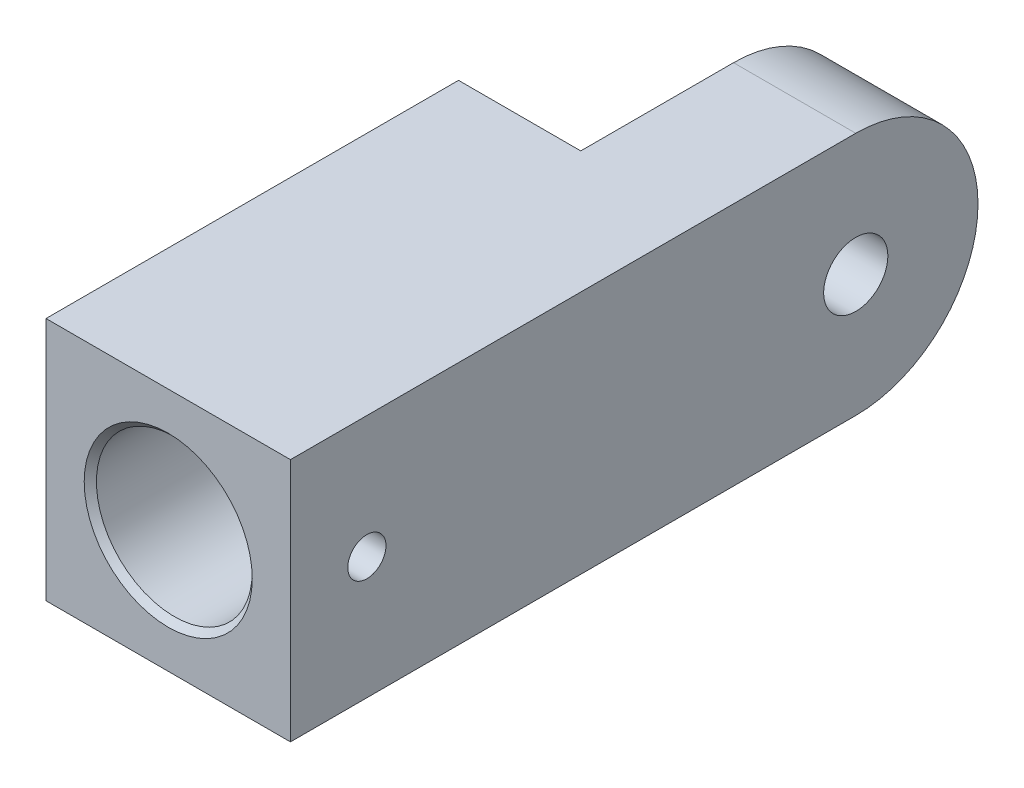
from build123d import *

# Parameters (mm, degrees)
SKETCH1_W                               = 16
SKETCH1_H                               = 16
BASE_DEPTH                              = 45
SKETCH3_W                               = 19.927362357
SKETCH3_H                               = 16
SLOTFORANOTHERPART_DEPTH                = 47.400431032
CHAMFERFORSLOT_DEPTH                    = 47.400431032
M5X0_8_TAPPED_HOLE_FOR_SLOTSCREW_D      = 4.2
M5X0_8_TAPPED_HOLE_FOR_SLOTSCREW_DEPTH  = 11.1381927
M5X0_8_TAPPED_HOLE_FOR_SLOTSCREW_TIP    = 1.2618073
M3X0_5_TAPPED_HOLE_FOR_ROD_FIXING_D     = 2.5
M3X0_5_TAPPED_HOLE_FOR_ROD_FIXING_DEPTH = 6.748924226
M3X0_5_TAPPED_HOLE_FOR_ROD_FIXING_TIP   = 0.751075774
F_10_2_10_2_ROD_HOLE_D                  = 10.2
F_10_2_10_2_ROD_HOLE_DEPTH              = 11.935610843
F_10_2_10_2_ROD_HOLE_CSINK_D            = 11
F_10_2_10_2_ROD_HOLE_CSINK_ANGLE        = 90
F_10_2_10_2_ROD_HOLE_TIP                = 3.064389157


with BuildPart() as part:
    # Sketch1 → Base (new body)
    with BuildSketch(Plane.XY):
        Rectangle(SKETCH1_W, SKETCH1_H)
    extrude(amount=BASE_DEPTH)

    # Sketch3 → SlotForAnotherPart (cut, through all)
    with BuildSketch(Plane(origin=(0, 0, 0), x_dir=(0, 0, -1), z_dir=(1, 0, 0))):
        with Locations((-8.036318822, 0)):
            Rectangle(SKETCH3_W, SKETCH3_H)
    extrude(amount=-SLOTFORANOTHERPART_DEPTH, mode=Mode.SUBTRACT)

    # Sketch3_3 → ChamferForSlot (cut, through all)
    with BuildSketch(Plane(origin=(0, 0, 0), x_dir=(0, 0, -1), z_dir=(1, 0, 0))):
        with BuildLine():
            Line((1.927362357, 8), (-8.000000039, 8))
            ThreePointArc((-8.000000039, 8), (-2.343145764, 5.656854263), (0, 0))
            ThreePointArc((0, 0), (-2.343145751, -5.656854249), (-8, -8))
            Line((-8, -8), (1.927362357, -8))
            Line((1.927362357, -8), (1.927362357, 8))
        make_face()
    extrude(amount=CHAMFERFORSLOT_DEPTH, mode=Mode.SUBTRACT)

    # M5x0.8 Tapped Hole for SlotScrew
    with Locations(Plane(origin=(8, 0, 0), x_dir=(0, 0, -1), z_dir=(1, 0, 0))):
        with Locations((-8, 0)):
            Hole(M5X0_8_TAPPED_HOLE_FOR_SLOTSCREW_D / 2, depth=M5X0_8_TAPPED_HOLE_FOR_SLOTSCREW_DEPTH)
            with Locations((0, 0, -(M5X0_8_TAPPED_HOLE_FOR_SLOTSCREW_DEPTH + M5X0_8_TAPPED_HOLE_FOR_SLOTSCREW_TIP / 2))):  # 118° drill point
                Cone(0, M5X0_8_TAPPED_HOLE_FOR_SLOTSCREW_D / 2, M5X0_8_TAPPED_HOLE_FOR_SLOTSCREW_TIP, mode=Mode.SUBTRACT)

    # M3x0.5 Tapped Hole for Rod Fixing
    with Locations(Plane(origin=(8, 0, 0), x_dir=(0, 0, -1), z_dir=(1, 0, 0))):
        with Locations((-40, 0)):
            Hole(M3X0_5_TAPPED_HOLE_FOR_ROD_FIXING_D / 2, depth=M3X0_5_TAPPED_HOLE_FOR_ROD_FIXING_DEPTH)
            with Locations((0, 0, -(M3X0_5_TAPPED_HOLE_FOR_ROD_FIXING_DEPTH + M3X0_5_TAPPED_HOLE_FOR_ROD_FIXING_TIP / 2))):  # 118° drill point
                Cone(0, M3X0_5_TAPPED_HOLE_FOR_ROD_FIXING_D / 2, M3X0_5_TAPPED_HOLE_FOR_ROD_FIXING_TIP, mode=Mode.SUBTRACT)

    # Ø10.2 (10.2) Rod Hole
    with Locations(Plane.XY.offset(45)):
        with Locations((0, 0)):
            CounterSinkHole(F_10_2_10_2_ROD_HOLE_D / 2, F_10_2_10_2_ROD_HOLE_CSINK_D / 2, depth=F_10_2_10_2_ROD_HOLE_DEPTH, counter_sink_angle=F_10_2_10_2_ROD_HOLE_CSINK_ANGLE)
            with Locations((0, 0, -(F_10_2_10_2_ROD_HOLE_DEPTH + F_10_2_10_2_ROD_HOLE_TIP / 2))):  # 118° drill point
                Cone(0, F_10_2_10_2_ROD_HOLE_D / 2, F_10_2_10_2_ROD_HOLE_TIP, mode=Mode.SUBTRACT)


solid = part.part
